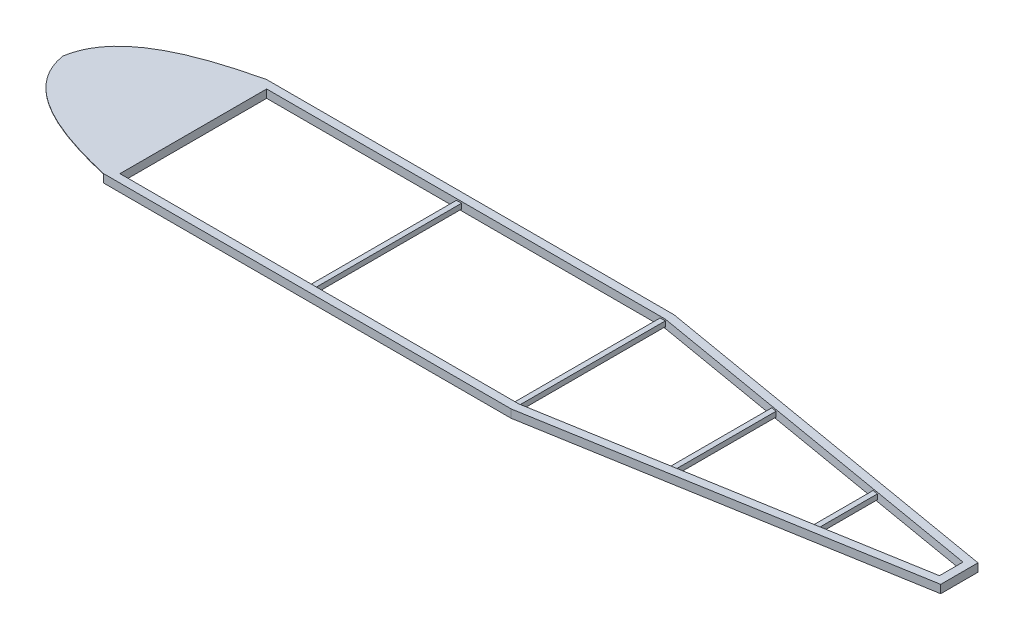
from build123d import *

# Parameters (mm, degrees)
BOSS_EXTRUDE1_DEPTH             = 50.8
CUT_EXTRUDE1_DEPTH              = 44.45
BOSS_EXTRUDE2_REACH             = 967.2
SKETCH3_W                       = 31.75
SKETCH3_H                       = 31.75
SKETCH3_W_2                     = 25.4
SKETCH3_H_2                     = 25.4
BOSS_EXTRUDE3_REACH             = 510
SKETCH8_W                       = 31.75
SKETCH8_H                       = 31.75
SKETCH8_W_2                     = 25.4
SKETCH8_H_2                     = 25.4
BOSS_EXTRUDE3_DIRECTION_2_REACH = 510
BOSS_EXTRUDE5_DEPTH             = 3.175


with BuildPart() as part:
    # Sketch1 → Boss-Extrude1 (new body)
    with BuildSketch(Plane(origin=(0, 0, 0), x_dir=(1, 0, 0), z_dir=(0, 1, 0))):
        Polygon((0, 508), (0, -508), (2540, -508), (4826, -116.205), (4826, 116.205), (2540, 508), align=None)
        Polygon((2535.678229605, 457.2), (50.8, 457.2), (50.8, -457.2), (2535.678229605, -457.2), (4775.2, -73.37085213), (4775.2, 73.37085213), align=None, mode=Mode.SUBTRACT)
    extrude(amount=BOSS_EXTRUDE1_DEPTH)

    # Sketch2 → Cut-Extrude1 (cut)
    with BuildSketch(Plane(origin=(0, 3.175, 0), x_dir=(1, 0, 0), z_dir=(0, 1, 0))):
        Polygon((3.175, -504.825), (2539.72988935, -504.825), (4822.825, -113.527865758), (4822.825, 113.527865758), (2539.72988935, 504.825), (3.175, 504.825), align=None)
        Polygon((2535.948340255, 460.375), (47.625, 460.375), (47.625, -460.375), (2535.948340255, -460.375), (4778.375, -76.047986372), (4778.375, 76.047986372), align=None, mode=Mode.SUBTRACT)
    extrude(amount=CUT_EXTRUDE1_DEPTH, mode=Mode.SUBTRACT)

    # Sketch3 → Boss-Extrude2 (add, up to next)
    with BuildSketch(Plane.XY.offset(-457.2), mode=Mode.PRIVATE) as boss_extrude2_sk1:
        with Locations((2519.803229605, 25.4)):
            Rectangle(SKETCH3_W, SKETCH3_H)
        with Locations((2519.803229605, 25.4)):
            Rectangle(SKETCH3_W_2, SKETCH3_H_2, mode=Mode.SUBTRACT)
    boss_extrude2_tool1 = extrude(boss_extrude2_sk1.sketch, amount=BOSS_EXTRUDE2_REACH, mode=Mode.PRIVATE) - part.part
    add(boss_extrude2_tool1.solids().sort_by_distance((2535.229217, 25.4, -457.2))[0])
    # Sketch3 → Boss-Extrude2 (add, up to next)
    with BuildSketch(Plane.XY.offset(-457.2), mode=Mode.PRIVATE) as boss_extrude2_sk2:
        with Locations((1249.803229605, 25.4)):
            Rectangle(SKETCH3_W, SKETCH3_H)
        with Locations((1249.803229605, 25.4)):
            Rectangle(SKETCH3_W_2, SKETCH3_H_2, mode=Mode.SUBTRACT)
    boss_extrude2_tool2 = extrude(boss_extrude2_sk2.sketch, amount=BOSS_EXTRUDE2_REACH, mode=Mode.PRIVATE) - part.part
    add(boss_extrude2_tool2.solids().sort_by_distance((1249.80323, 40.825987, -457.2))[0])


with BuildPart() as body_2:

    # Sketch8 → Boss-Extrude3 (new body, up to next)
    with BuildSketch(Plane.XY, mode=Mode.PRIVATE) as boss_extrude3_sk1:
        with Locations((3352.8, 25.4)):
            Rectangle(SKETCH8_W, SKETCH8_H)
        with Locations((3352.8, 25.4)):
            Rectangle(SKETCH8_W_2, SKETCH8_H_2, mode=Mode.SUBTRACT)
    boss_extrude3_tool1 = extrude(boss_extrude3_sk1.sketch, amount=BOSS_EXTRUDE3_REACH, mode=Mode.PRIVATE) - part.part
    add(boss_extrude3_tool1.solids().sort_by_distance((3352.8, 40.825987, 0))[0])
    # Sketch8 → Boss-Extrude3 (new body, up to next)
    with BuildSketch(Plane.XY, mode=Mode.PRIVATE) as boss_extrude3_sk2:
        with Locations((4114.8, 25.4)):
            Rectangle(SKETCH8_W, SKETCH8_H)
        with Locations((4114.8, 25.4)):
            Rectangle(SKETCH8_W_2, SKETCH8_H_2, mode=Mode.SUBTRACT)
    boss_extrude3_tool2 = extrude(boss_extrude3_sk2.sketch, amount=BOSS_EXTRUDE3_REACH, mode=Mode.PRIVATE) - part.part
    add(boss_extrude3_tool2.solids().sort_by_distance((4114.8, 40.825987, 0))[0])


    # Sketch8 → Boss-Extrude3 direction 2 (add, up to next)
    with BuildSketch(Plane.XY, mode=Mode.PRIVATE) as boss_extrude3_direction_2_sk1:
        with Locations((3352.8, 25.4)):
            Rectangle(SKETCH8_W, SKETCH8_H)
        with Locations((3352.8, 25.4)):
            Rectangle(SKETCH8_W_2, SKETCH8_H_2, mode=Mode.SUBTRACT)
    boss_extrude3_direction_2_tool1 = extrude(boss_extrude3_direction_2_sk1.sketch, amount=-BOSS_EXTRUDE3_DIRECTION_2_REACH, mode=Mode.PRIVATE) - part.part
    add(boss_extrude3_direction_2_tool1.solids().sort_by_distance((3352.8, 40.825987, 0))[0])
    # Sketch8 → Boss-Extrude3 direction 2 (add, up to next)
    with BuildSketch(Plane.XY, mode=Mode.PRIVATE) as boss_extrude3_direction_2_sk2:
        with Locations((4114.8, 25.4)):
            Rectangle(SKETCH8_W, SKETCH8_H)
        with Locations((4114.8, 25.4)):
            Rectangle(SKETCH8_W_2, SKETCH8_H_2, mode=Mode.SUBTRACT)
    boss_extrude3_direction_2_tool2 = extrude(boss_extrude3_direction_2_sk2.sketch, amount=-BOSS_EXTRUDE3_DIRECTION_2_REACH, mode=Mode.PRIVATE) - part.part
    add(boss_extrude3_direction_2_tool2.solids().sort_by_distance((4114.8, 40.825987, 0))[0])


with BuildPart() as part_1:
    add(part.part)

    # Sketch11 → Boss-Extrude5 (add)
    with BuildSketch(Plane(origin=(0, 50.8, 0), x_dir=(1, 0, 0), z_dir=(0, 1, 0))):
        with BuildLine():
            Line((0, 508), (0, -508))
            add(Edge.make_bspline(
                [(-762, 0), (-716.49643682, -292.478097615), (-357.636604654, -425.270631445), (0, -508)],
                knots=[0, 0, 0, 0, 1, 1, 1, 1], degree=3))
            add(Edge.make_bspline(
                [(-762, 0), (-716.49643682, 292.478097615), (-357.636604654, 425.270631445), (0, 508)],
                knots=[0, 0, 0, 0, 1, 1, 1, 1], degree=3))
        make_face()
    extrude(amount=-BOSS_EXTRUDE5_DEPTH)


solid = Compound([body_2.part, part_1.part])
